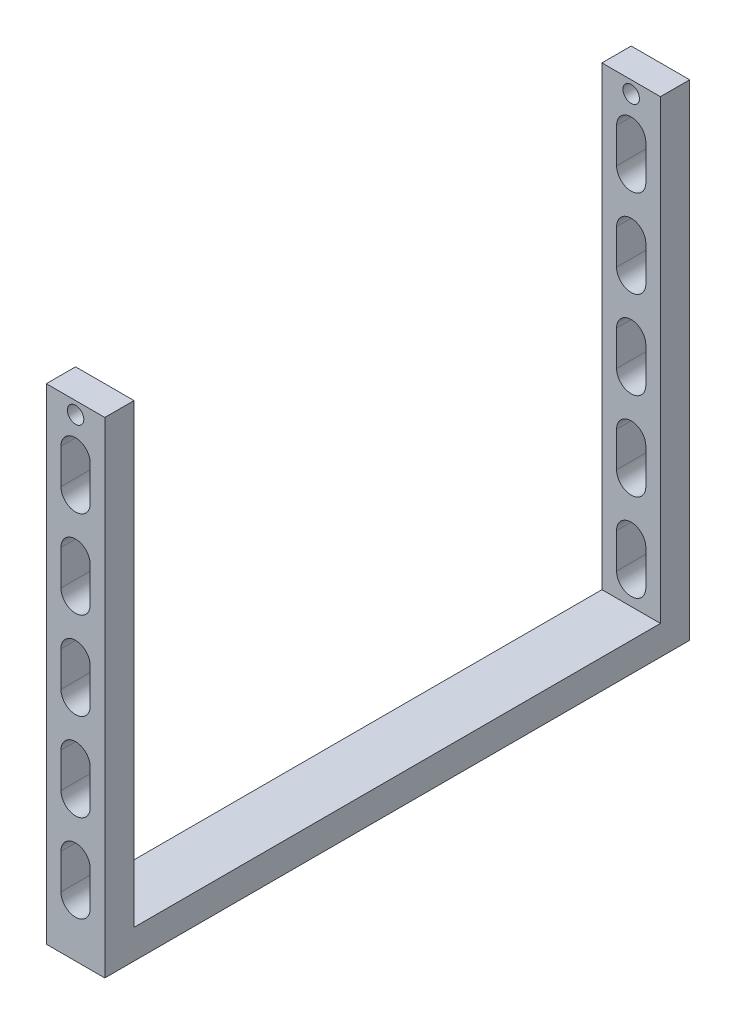
from build123d import *

# Parameters (mm, degrees)
SKETCH1_W                       = 12.7
SKETCH1_H                       = 6.35
BOSS_EXTRUDE1_DEPTH             = 105.41
SKETCH2_W                       = 12.7
SKETCH2_H                       = 6.35
BOSS_EXTRUDE2_DEPTH             = 127
SKETCH3_W                       = 12.7
SKETCH3_H                       = 6.35
BOSS_EXTRUDE3_DEPTH             = 105.41
CUT_EXTRUDE1_DEPTH              = 128
LPATTERN1_COUNT                 = 5
LPATTERN1_PITCH                 = 19.05
F_9_64_0_14063_DIAMETER_HOLE1_D = 3.572002


with BuildPart() as part:
    # Sketch1 → Boss-Extrude1 (new body)
    with BuildSketch(Plane(origin=(0, 0, 0), x_dir=(1, 0, 0), z_dir=(0, 1, 0))):
        Rectangle(SKETCH1_W, SKETCH1_H)
    extrude(amount=-BOSS_EXTRUDE1_DEPTH)

    # Sketch2 → Boss-Extrude2 (add)
    with BuildSketch(Plane.XY.offset(3.175)):
        with Locations((0, -102.235)):
            Rectangle(SKETCH2_W, SKETCH2_H)
    extrude(amount=-BOSS_EXTRUDE2_DEPTH)

    # Sketch3 → Boss-Extrude3 (add)
    with BuildSketch(Plane.XZ.offset(105.41)):
        with Locations((0, -120.65)):
            Rectangle(SKETCH3_W, SKETCH3_H)
    extrude(amount=-BOSS_EXTRUDE3_DEPTH)

    # Sketch4 → Cut-Extrude1 (cut, through all)
    with BuildSketch(Plane(origin=(0, 0, -123.825), x_dir=(-1, 0, 0), z_dir=(0, 0, -1))):
        with BuildLine():
            Line((3.175, -10.16), (3.175, -17.78))
            ThreePointArc((3.175, -17.78), (0, -20.955), (-3.175, -17.78))
            Line((-3.175, -17.78), (-3.175, -10.16))
            ThreePointArc((-3.175, -10.16), (0, -6.985), (3.175, -10.16))
        make_face()
    cut_extrude1 = extrude(amount=-CUT_EXTRUDE1_DEPTH, mode=Mode.SUBTRACT)

    # LPattern1: Cut-Extrude1 ×5
    with Locations(*[(0, -i * LPATTERN1_PITCH, 0) for i in range(1, LPATTERN1_COUNT)]):
        add(cut_extrude1, mode=Mode.SUBTRACT)

    # 9/64 (0.14063) Diameter Hole1 (through all)
    with Locations(Plane(origin=(0, 0, -123.825), x_dir=(-1, 0, 0), z_dir=(0, 0, -1))):
        with Locations((0, -2.667)):
            Hole(F_9_64_0_14063_DIAMETER_HOLE1_D / 2)


solid = part.part
